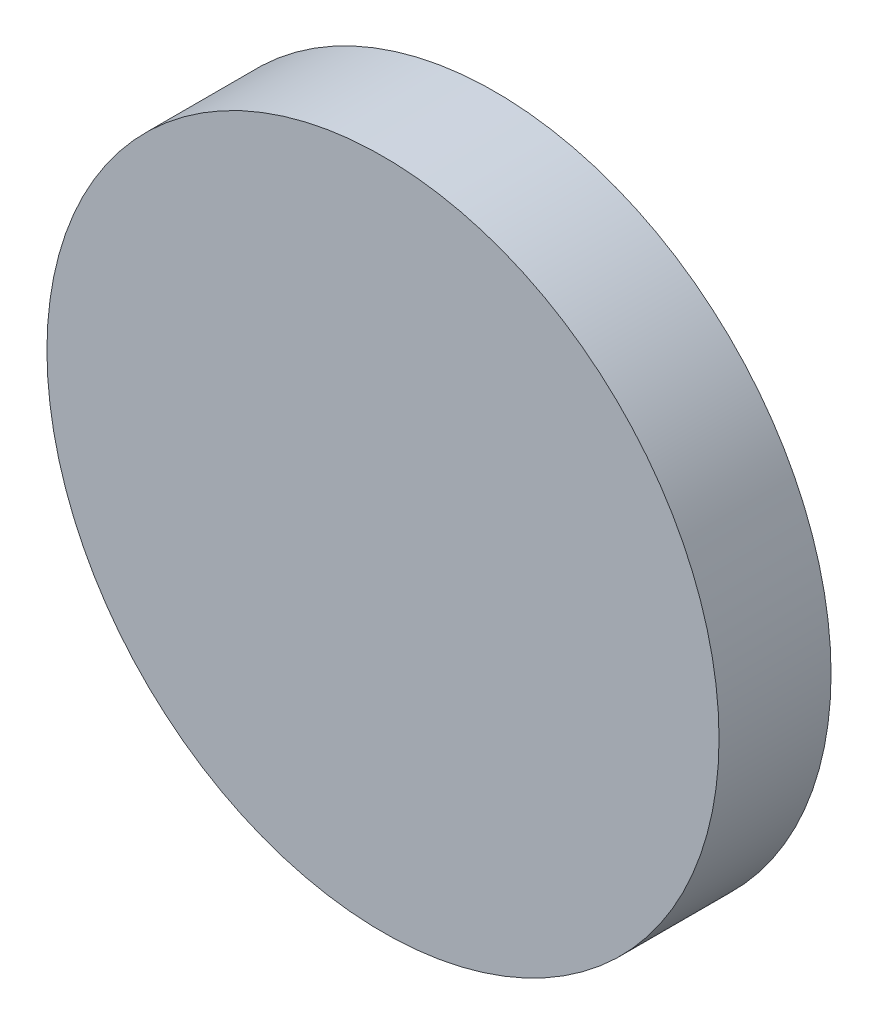
from build123d import *

# Parameters (mm, degrees)
SKETCH1_R           = 6
BOSS_EXTRUDE1_DEPTH = 2


with BuildPart() as part:
    # Sketch1 → Boss-Extrude1 (new body)
    with BuildSketch(Plane.XY):
        Circle(SKETCH1_R)
    extrude(amount=BOSS_EXTRUDE1_DEPTH)


solid = part.part
